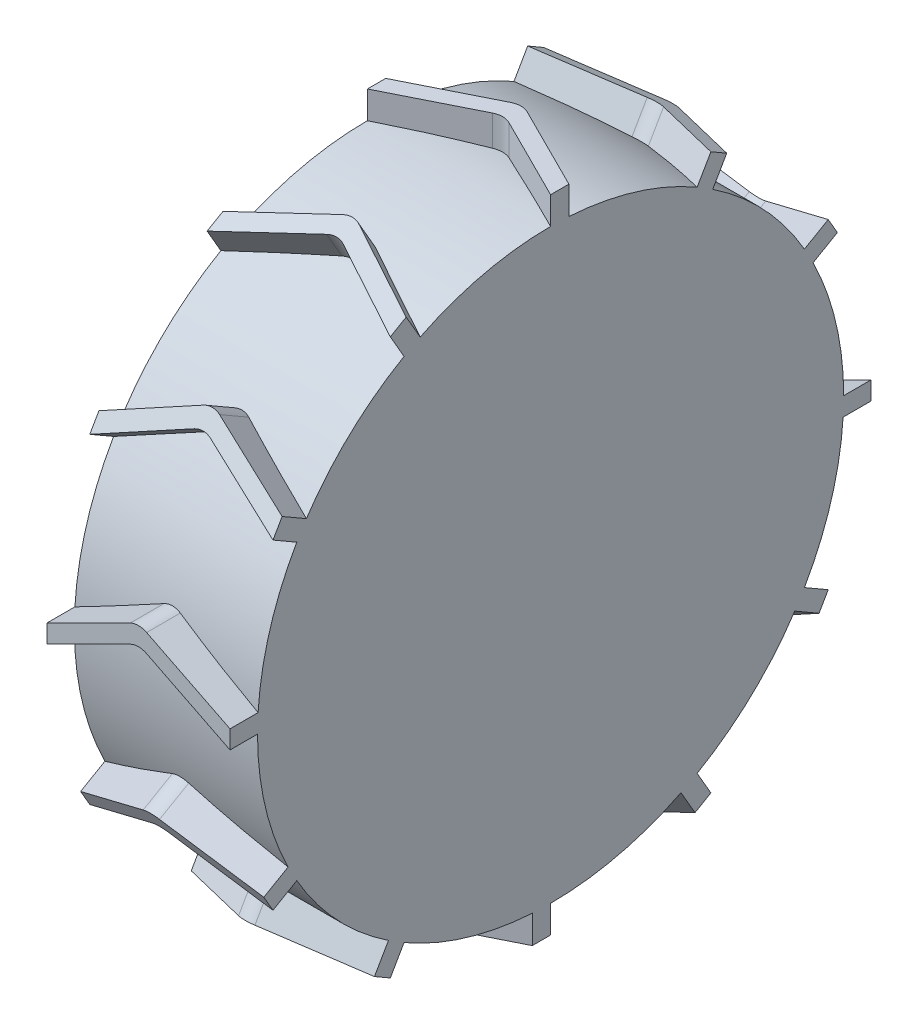
from build123d import *

# Parameters (mm, degrees)
SKETCH2_R           = 159.99660676
BOSS_EXTRUDE1_DEPTH = 100
BOSS_EXTRUDE2_DEPTH = 175
CIRPATTERN2_COUNT   = 12


with BuildPart() as part:
    # Sketch2 → Boss-Extrude1 (new body)
    with BuildSketch(Plane(origin=(0, 0, 0), x_dir=(0, 0, -1), z_dir=(1, 0, 0))):
        Circle(SKETCH2_R)
    extrude(amount=BOSS_EXTRUDE1_DEPTH)

    # Sketch4 → Boss-Extrude2 (add)
    with BuildSketch(Plane(origin=(0, 0, 0), x_dir=(1, 0, 0), z_dir=(0, 1, 0))):
        with BuildLine():
            Line((0, 0), (45.527864045, 22.763932023))
            ThreePointArc((45.527864045, 22.763932023), (50, 23.819660113), (54.472135955, 22.763932023))
            Line((54.472135955, 22.763932023), (100, 0))
            Line((100, 0), (100, 10))
            Line((100, 10), (54.472135955, 32.763932023))
            ThreePointArc((54.472135955, 32.763932023), (50, 33.819660113), (45.527864045, 32.763932023))
            Line((45.527864045, 32.763932023), (0, 10))
            Line((0, 10), (0, 0))
        make_face()
    boss_extrude2 = extrude(amount=BOSS_EXTRUDE2_DEPTH)

    # CirPattern2: Boss-Extrude2 ×12 about axis
    cirpattern2_axis = Axis((0, 0, 0), (1, 0, 0))
    for i in range(1, CIRPATTERN2_COUNT):
        add(boss_extrude2.rotate(cirpattern2_axis, i * 360 / CIRPATTERN2_COUNT))


solid = part.part
